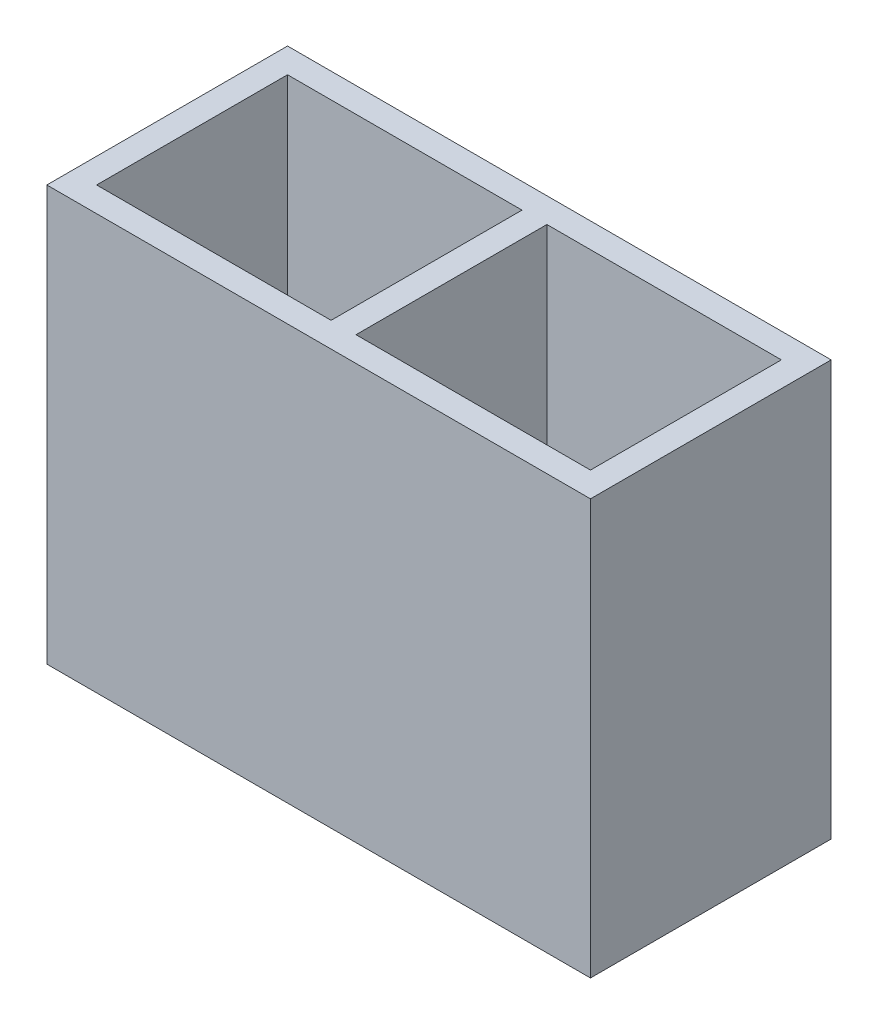
from build123d import *

# Parameters (mm, degrees)
SKETCH1_W               = 13.1
SKETCH1_H               = 5.8
BOSS_EXTRUDE1_DEPTH     = 5
SKETCH10_W              = 5.65
SKETCH10_H              = 4.6
CUT_EXTRUDE7_DEPTH      = 6.6
SKETCH9_R               = 0.75
CUT_EXTRUDE6_DEPTH      = 6
CUT_EXTRUDE6_DEPTH_BACK = 6


with BuildPart() as part:
    # Sketch1 → Boss-Extrude1 (new body, symmetric)
    with BuildSketch(Plane(origin=(0, 0, 0), x_dir=(1, 0, 0), z_dir=(0, 1, 0))):
        Rectangle(SKETCH1_W, SKETCH1_H)
    extrude(amount=BOSS_EXTRUDE1_DEPTH, both=True)

    # Sketch10 → Cut-Extrude7 (cut)
    with BuildSketch(Plane(origin=(0, 5, 0), x_dir=(1, 0, 0), z_dir=(0, 1, 0))):
        with Locations((-3.125, 0)):
            Rectangle(SKETCH10_W, SKETCH10_H)
        with Locations((3.125, 0)):
            Rectangle(SKETCH10_W, SKETCH10_H)
    extrude(amount=-CUT_EXTRUDE7_DEPTH, mode=Mode.SUBTRACT)

    # Sketch9 → Cut-Extrude6 (cut, two sides)
    with BuildSketch(Plane(origin=(0, 0, 0), x_dir=(1, 0, 0), z_dir=(0, 1, 0))) as cut_extrude6_sk:
        with Locations((-4.625, 0)):
            Circle(SKETCH9_R)
        with Locations((-1.625, 0)):
            Circle(SKETCH9_R)
        with Locations((1.625, 0)):
            Circle(SKETCH9_R)
        with Locations((4.625, 0)):
            Circle(SKETCH9_R)
    extrude(amount=CUT_EXTRUDE6_DEPTH, mode=Mode.SUBTRACT)
    extrude(cut_extrude6_sk.sketch, amount=-CUT_EXTRUDE6_DEPTH_BACK, mode=Mode.SUBTRACT)


solid = part.part
